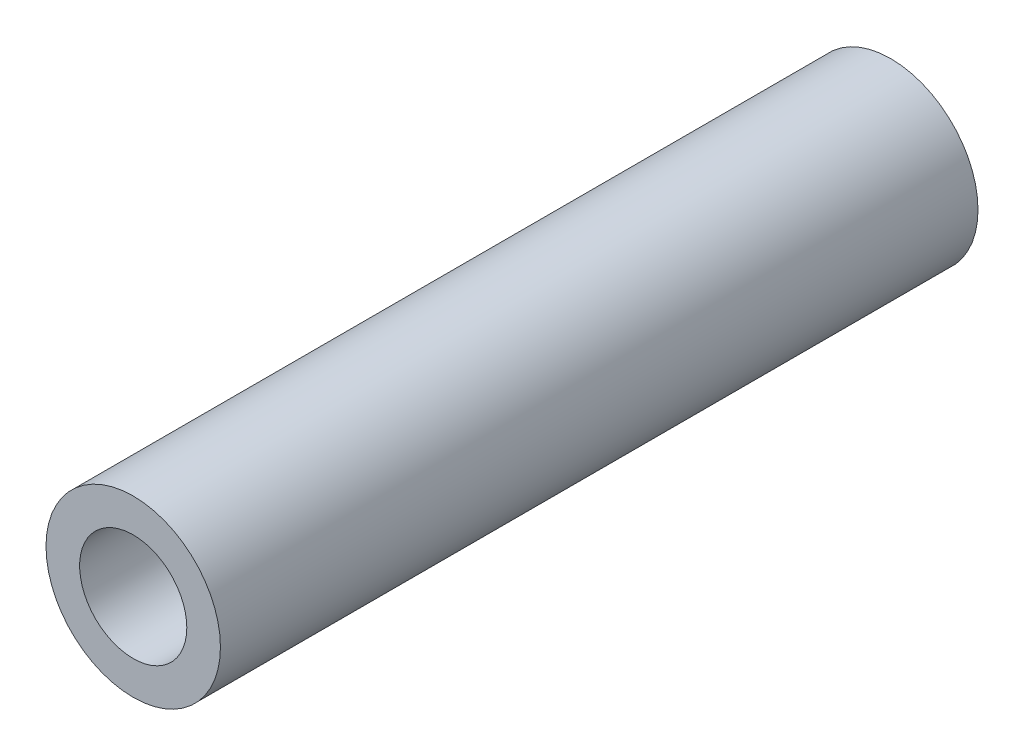
from build123d import *

# Parameters (mm, degrees)
SKETCH_1_R      = 3.5
SKETCH_1_R_2    = 2.15
EXTRUDE_1_DEPTH = 30.4


with BuildPart() as part:
    # 草图1 → 凸台-拉伸1 (new body)
    with BuildSketch(Plane.XY):
        Circle(SKETCH_1_R)
        Circle(SKETCH_1_R_2, mode=Mode.SUBTRACT)
    extrude(amount=EXTRUDE_1_DEPTH)


solid = part.part
